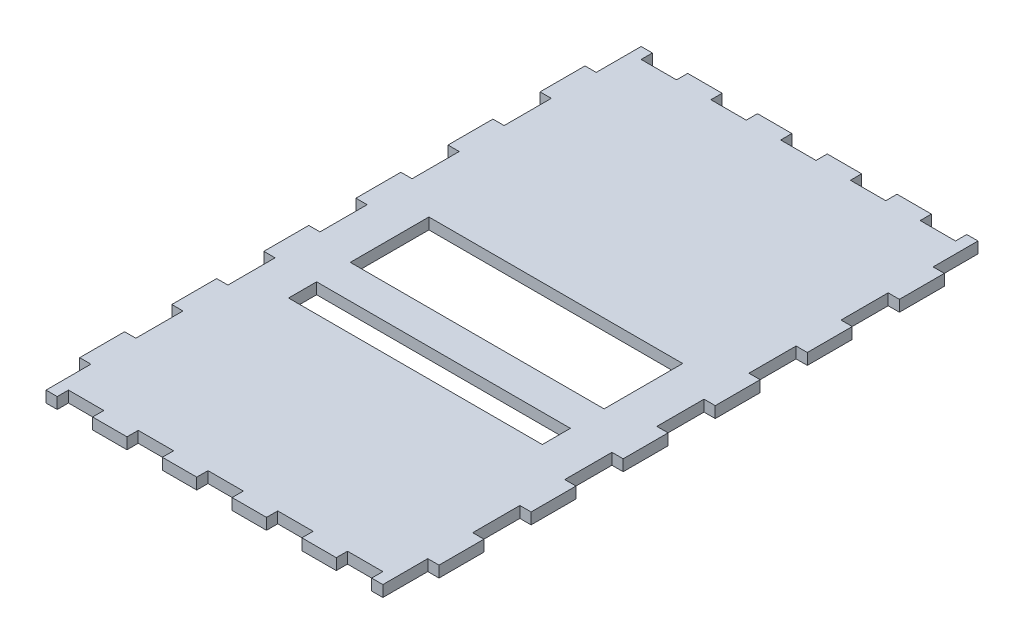
from build123d import *

# Parameters (mm, degrees)
BOSS_EXTRUDE1_DEPTH = 5
SKETCH2_W           = 113
SKETCH2_H           = 35
SKETCH2_H_2         = 12.5
CUT_EXTRUDE1_DEPTH  = 10


with BuildPart() as part:
    # Sketch1 → Boss-Extrude1 (new body)
    with BuildSketch(Plane(origin=(0, 0, 0), x_dir=(1, 0, 0), z_dir=(0, 1, 0))):
        Polygon((-80, 71.5), (-80, 51.5), (-75, 51.5), (-75, 30.5), (-80, 30.5), (-80, 10.5), (-75, 10.5), (-75, -10.5), (-80, -10.5), (-80, -30.5), (-75, -30.5), (-75, -51.5), (-80, -51.5), (-80, -71.5), (-75, -71.5), (-75, -92.5), (-80, -92.5), (-80, -112.5), (-75, -112.5), (-75, -132.5), (-70, -132.5), (-70, -127.5), (-54.25, -127.5), (-54.25, -132.5), (-38.9375, -132.5), (-38.9375, -127.5), (-23.1875, -127.5), (-23.1875, -132.5), (-7.875, -132.5), (-7.875, -127.5), (7.875, -127.5), (7.875, -132.5), (23.1875, -132.5), (23.1875, -127.5), (38.9375, -127.5), (38.9375, -132.5), (54.25, -132.5), (54.25, -127.5), (70, -127.5), (70, -132.5), (75, -132.5), (75, -112.5), (80, -112.5), (80, -92.5), (75, -92.5), (75, -71.5), (80, -71.5), (80, -51.5), (75, -51.5), (75, -30.5), (80, -30.5), (80, -10.5), (75, -10.5), (75, 10.5), (80, 10.5), (80, 30.5), (75, 30.5), (75, 51.5), (80, 51.5), (80, 71.5), (75, 71.5), (75, 92.5), (80, 92.5), (80, 112.5), (75, 112.5), (75, 132.5), (70, 132.5), (70, 127.5), (54.25, 127.5), (54.25, 132.5), (38.9375, 132.5), (38.9375, 127.5), (23.1875, 127.5), (23.1875, 132.5), (7.875, 132.5), (7.875, 127.5), (-7.875, 127.5), (-7.875, 132.5), (-23.1875, 132.5), (-23.1875, 127.5), (-38.9375, 127.5), (-38.9375, 132.5), (-54.25, 132.5), (-54.25, 127.5), (-70, 127.5), (-70, 132.5), (-75, 132.5), (-75, 112.5), (-80, 112.5), (-80, 92.5), (-75, 92.5), (-75, 71.5), align=None)
    extrude(amount=BOSS_EXTRUDE1_DEPTH)

    # Sketch2 → Cut-Extrude1 (cut)
    with BuildSketch(Plane(origin=(0, 5, 0), x_dir=(1, 0, 0), z_dir=(0, 1, 0))):
        with Locations((0, 2)):
            Rectangle(SKETCH2_W, SKETCH2_H)
        with Locations((0, -36.75)):
            Rectangle(SKETCH2_W, SKETCH2_H_2)
    extrude(amount=-CUT_EXTRUDE1_DEPTH, mode=Mode.SUBTRACT)


solid = part.part
